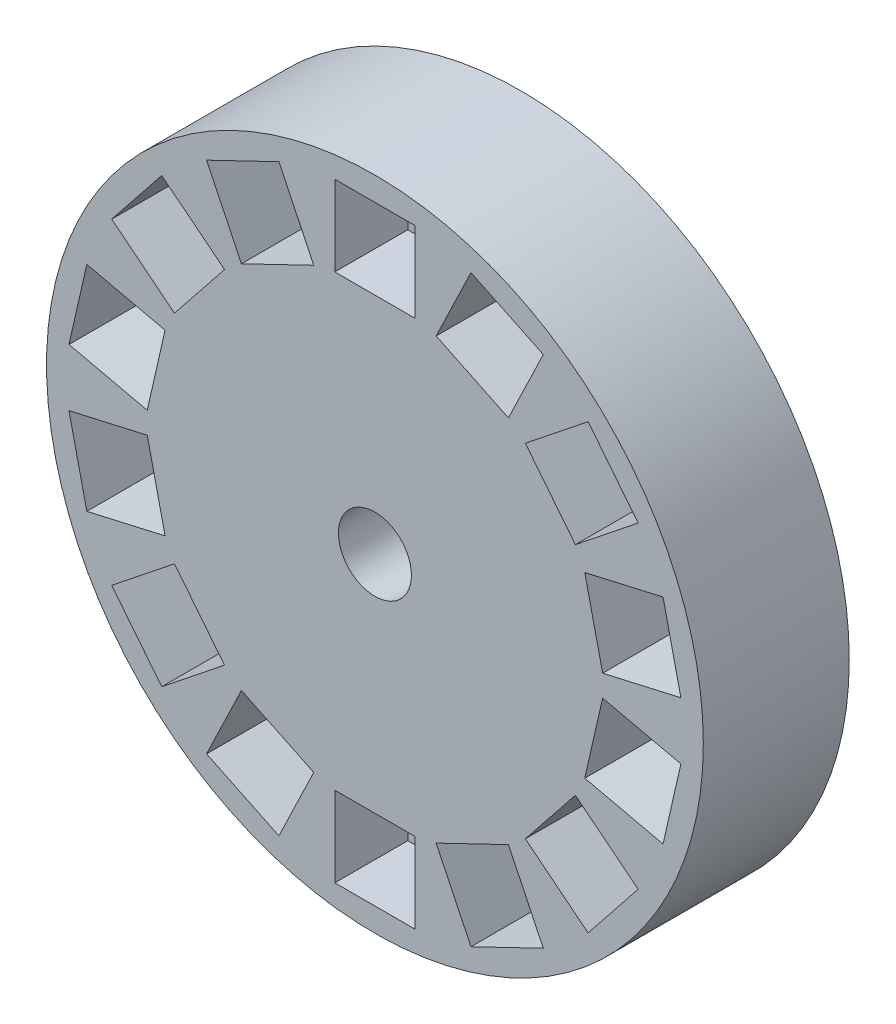
from build123d import *

# Parameters (mm, degrees)
SZKIC1_R                    = 4.5
SZKIC1_R_2                  = 0.5
DODANIE_WYCI_GNI_CIE1_DEPTH = 2
SZKIC2_W                    = 1.1
SZKIC2_H                    = 1.1
WYTNIJ_WYCI_GNI_CIE1_DEPTH  = 1


with BuildPart() as part:
    # Szkic1 → Dodanie-wyciągnięcie1 (new body)
    with BuildSketch(Plane.XY):
        Circle(SZKIC1_R)
        Circle(SZKIC1_R_2, mode=Mode.SUBTRACT)
    extrude(amount=DODANIE_WYCI_GNI_CIE1_DEPTH)

    # Szkic2 → Wytnij-wyciągnięcie1 (cut)
    with BuildSketch(Plane.XY.offset(2)):
        Polygon((1.315931733, 4.00018108), (0.83865962, 3.009115325), (1.829725375, 2.531843212), (2.306997488, 3.522908967), align=None)
        with Locations((0, 3.625)):
            Rectangle(SZKIC2_W, SZKIC2_H)
        Polygon((2.921227048, 3.033077238), (2.061212418, 2.347238456), (2.7470512, 1.487223825), (3.60706583, 2.173062607), align=None)
        Polygon((3.94793752, 1.465235251), (2.875516816, 1.220462224), (3.120289844, 0.14804152), (4.192710547, 0.392814548), align=None)
        Polygon((4.192710547, -0.392814548), (3.120289844, -0.14804152), (2.875516816, -1.220462224), (3.94793752, -1.465235251), align=None)
        Polygon((3.60706583, -2.173062607), (2.7470512, -1.487223825), (2.061212418, -2.347238456), (2.921227048, -3.033077238), align=None)
        Polygon((2.306997488, -3.522908967), (1.829725375, -2.531843212), (0.83865962, -3.009115325), (1.315931733, -4.00018108), align=None)
        with Locations((0, -3.625)):
            Rectangle(SZKIC2_W, SZKIC2_H)
        Polygon((-1.315931733, -4.00018108), (-0.83865962, -3.009115325), (-1.829725375, -2.531843212), (-2.306997488, -3.522908967), align=None)
        Polygon((-2.921227048, -3.033077238), (-2.061212418, -2.347238456), (-2.7470512, -1.487223825), (-3.60706583, -2.173062607), align=None)
        Polygon((-3.94793752, -1.465235251), (-2.875516816, -1.220462224), (-3.120289844, -0.14804152), (-4.192710547, -0.392814548), align=None)
        Polygon((-4.192710547, 0.392814548), (-3.120289844, 0.14804152), (-2.875516816, 1.220462224), (-3.94793752, 1.465235251), align=None)
        Polygon((-3.60706583, 2.173062607), (-2.7470512, 1.487223825), (-2.061212418, 2.347238456), (-2.921227048, 3.033077238), align=None)
        Polygon((-2.306997488, 3.522908967), (-1.829725375, 2.531843212), (-0.83865962, 3.009115325), (-1.315931733, 4.00018108), align=None)
    extrude(amount=-WYTNIJ_WYCI_GNI_CIE1_DEPTH, mode=Mode.SUBTRACT)


solid = part.part
